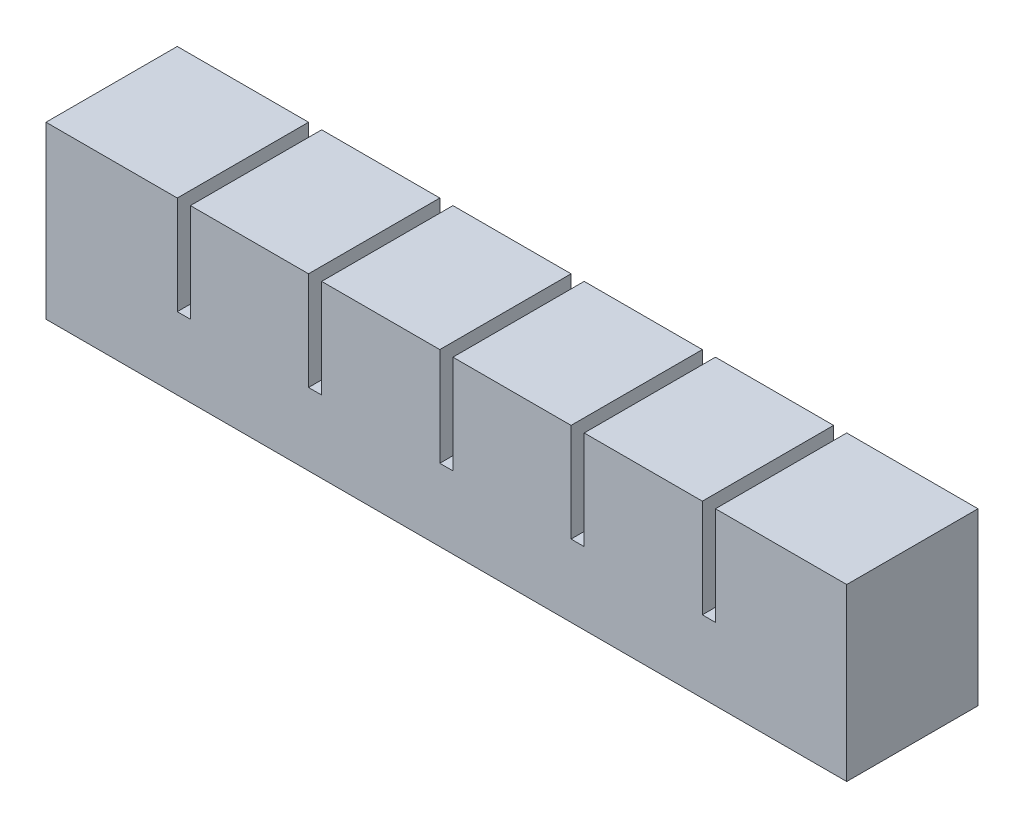
from build123d import *

# Parameters (mm, degrees)
SKETCH1_W           = 18
SKETCH1_H           = 20
BOSS_EXTRUDE1_DEPTH = 20
SKETCH2_W           = 10
SKETCH2_H           = 12
CUT_EXTRUDE1_DEPTH  = 16
SKETCH3_W           = 20
SKETCH3_H           = 5
BOSS_EXTRUDE2_DEPTH = 2
LPATTERN1_COUNT     = 6
LPATTERN1_PITCH     = 20
SKETCH4_W           = 20
SKETCH4_H           = 15
BOSS_EXTRUDE3_DEPTH = 2
SKETCH5_W           = 20
SKETCH5_H           = 20
BOSS_EXTRUDE4_DEPTH = 2
SKETCH6_W           = 110
SKETCH6_H           = 2
CUT_EXTRUDE2_DEPTH  = 2
SKETCH7_W           = 122
SKETCH7_H           = 20
BOSS_EXTRUDE5_DEPTH = 6


with BuildPart() as part:
    # Sketch1 → Boss-Extrude1 (new body)
    with BuildSketch(Plane.XY):
        with Locations((9, 10)):
            Rectangle(SKETCH1_W, SKETCH1_H)
    extrude(amount=BOSS_EXTRUDE1_DEPTH)

    # Sketch2 → Cut-Extrude1 (cut)
    with BuildSketch(Plane.XZ):
        with Locations((9, 10)):
            Rectangle(SKETCH2_W, SKETCH2_H)
    extrude(amount=-CUT_EXTRUDE1_DEPTH, mode=Mode.SUBTRACT)

    # Sketch3 → Boss-Extrude2 (add)
    with BuildSketch(Plane(origin=(18, 0, 0), x_dir=(0, 0, -1), z_dir=(1, 0, 0))):
        with Locations((-10, 2.5)):
            Rectangle(SKETCH3_W, SKETCH3_H)
    extrude(amount=BOSS_EXTRUDE2_DEPTH)


with BuildPart() as lpattern1_1:
    # LPattern1: pattern copy
    add(part.part.moved(Location(Vector(1, 0, 0) * (1 * LPATTERN1_PITCH))))


with BuildPart() as lpattern1_2:
    # LPattern1: pattern copy
    add(part.part.moved(Location(Vector(1, 0, 0) * (2 * LPATTERN1_PITCH))))


with BuildPart() as lpattern1_3:
    # LPattern1: pattern copy
    add(part.part.moved(Location(Vector(1, 0, 0) * (3 * LPATTERN1_PITCH))))


with BuildPart() as lpattern1_4:
    # LPattern1: pattern copy
    add(part.part.moved(Location(Vector(1, 0, 0) * (4 * LPATTERN1_PITCH))))


with BuildPart() as lpattern1_5:
    # LPattern1: pattern copy
    add(part.part.moved(Location(Vector(1, 0, 0) * (5 * LPATTERN1_PITCH))))

    # Sketch4 → Boss-Extrude3 (add)
    with BuildSketch(Plane(origin=(118, 0, 0), x_dir=(0, 0, -1), z_dir=(1, 0, 0))):
        with Locations((-10, 12.5)):
            Rectangle(SKETCH4_W, SKETCH4_H)
    extrude(amount=BOSS_EXTRUDE3_DEPTH)


with BuildPart() as part_1:
    add(part.part)

    # Sketch5 → Boss-Extrude4 (add)
    with BuildSketch(Plane.ZY):
        with Locations((10, 10)):
            Rectangle(SKETCH5_W, SKETCH5_H)
    extrude(amount=BOSS_EXTRUDE4_DEPTH)


with BuildPart() as lpattern1_1_1:
    add(lpattern1_1.part)

    # Combine1: union LPattern1_2, LPattern1_3, LPattern1_4, part, LPattern1_5
    add(lpattern1_2.part)
    add(lpattern1_3.part)
    add(lpattern1_4.part)
    add(part_1.part)
    add(lpattern1_5.part)

    # Sketch6 → Cut-Extrude2 (cut)
    with BuildSketch(Plane.XZ):
        with Locations((59, 10)):
            Rectangle(SKETCH6_W, SKETCH6_H)
    extrude(amount=-CUT_EXTRUDE2_DEPTH, mode=Mode.SUBTRACT)

    # Sketch7 → Boss-Extrude5 (add)
    with BuildSketch(Plane.XZ):
        with Locations((59, 10)):
            Rectangle(SKETCH7_W, SKETCH7_H)
    extrude(amount=BOSS_EXTRUDE5_DEPTH)


solid = lpattern1_1_1.part
